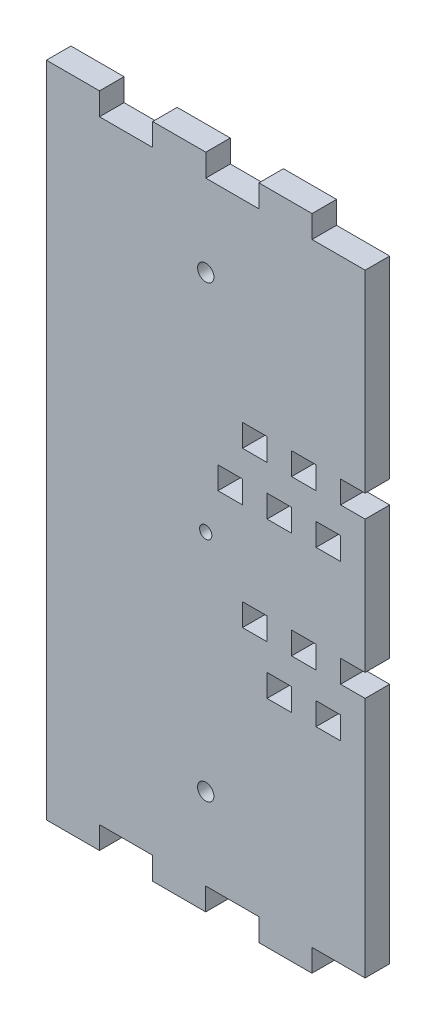
from build123d import *

# Parameters (mm, degrees)
MODEL_R             = 2
MODEL_R_2           = 1.5
BOSS_EXTRUDE1_DEPTH = 6


with BuildPart() as part:
    # Model → Boss-Extrude1 (new body)
    with BuildSketch(Plane.XY):
        Polygon((136.503533409, 63.253129949), (136.50298126, 57.754435229), (123.504343338, 57.752522637), (123.503533606, 63.255740591), (110.504895018, 63.258351095), (110.504341961, 57.750609844), (97.50570415, 57.760961628), (97.504895084, 63.259656484), (84.506256496, 63.262266989), (84.505704216, 57.762267017), (71.507065628, 57.764877521), (71.508169139, 63.259656429), (71.52323132, 218.754434691), (84.52187017, 218.754434691), (84.52131789, 213.254434719), (97.51995674, 213.254434719), (97.521870105, 218.753129302), (110.520509732, 218.760870582), (110.519956675, 213.25312933), (123.518595525, 213.25312933), (123.520510463, 218.75634701), (136.519147739, 218.751823913), (136.51859559, 213.253129193), (149.517234309, 213.251823941), (149.512489722, 166.001824179), (143.512489752, 166.002426666), (143.512213612, 163.25242668), (143.511937472, 160.502426694), (149.511937442, 160.501824207), (149.50867397, 128.001824371), (143.508674, 128.002426858), (143.50839786, 125.252426872), (143.50812172, 122.502426886), (149.502172128, 122.501824996), (149.502172128, 63.251824697), align=None)
        with Locations((110.507816209, 83.257045523)):
            Circle(MODEL_R, mode=Mode.SUBTRACT)
        with Locations((110.518861547, 193.254434719)):
            Circle(MODEL_R, mode=Mode.SUBTRACT)
        with Locations((110.507264687, 138.255740731)):
            Circle(MODEL_R_2, mode=Mode.SUBTRACT)
        Polygon((119.512213733, 163.254836629), (119.512489873, 166.004836615), (125.512489843, 166.004234128), (125.511937563, 160.504234156), (119.511937593, 160.504836643), align=None, mode=Mode.SUBTRACT)
        Polygon((131.512213673, 163.253631655), (131.512489813, 166.003631641), (137.512489783, 166.003029154), (137.511937503, 160.503029181), (131.511937533, 160.503631669), align=None, mode=Mode.SUBTRACT)
        Polygon((113.511008789, 151.255439177), (113.511284929, 154.005439163), (119.511284899, 154.004836676), (119.510732619, 148.504836703), (113.510732649, 148.505439191), align=None, mode=Mode.SUBTRACT)
        Polygon((125.511008729, 151.254234202), (125.511284869, 154.004234189), (131.511284838, 154.003631701), (131.510732558, 148.503631729), (125.510732589, 148.504234216), align=None, mode=Mode.SUBTRACT)
        Polygon((137.511008668, 151.253029228), (137.511284808, 154.003029214), (143.511284778, 154.002426727), (143.510732498, 148.502426755), (137.510732528, 148.503029242), align=None, mode=Mode.SUBTRACT)
        Polygon((119.508397981, 125.254836821), (119.508674121, 128.004836807), (125.508674091, 128.00423432), (125.508121811, 122.504234347), (119.508121841, 122.504836835), align=None, mode=Mode.SUBTRACT)
        Polygon((131.50839792, 125.253631846), (131.50867406, 128.003631832), (137.50867403, 128.003029345), (137.50812175, 122.503029373), (131.50812178, 122.50363186), align=None, mode=Mode.SUBTRACT)
        Polygon((125.507192976, 113.254234394), (125.507469116, 116.00423438), (131.507469086, 116.003631893), (131.506916806, 110.503631921), (125.506916836, 110.504234408), align=None, mode=Mode.SUBTRACT)
        Polygon((137.507192916, 113.253029419), (137.507469056, 116.003029406), (143.507469025, 116.002426918), (143.506916745, 110.502426946), (137.506916776, 110.503029433), align=None, mode=Mode.SUBTRACT)
    extrude(amount=BOSS_EXTRUDE1_DEPTH)


solid = part.part
